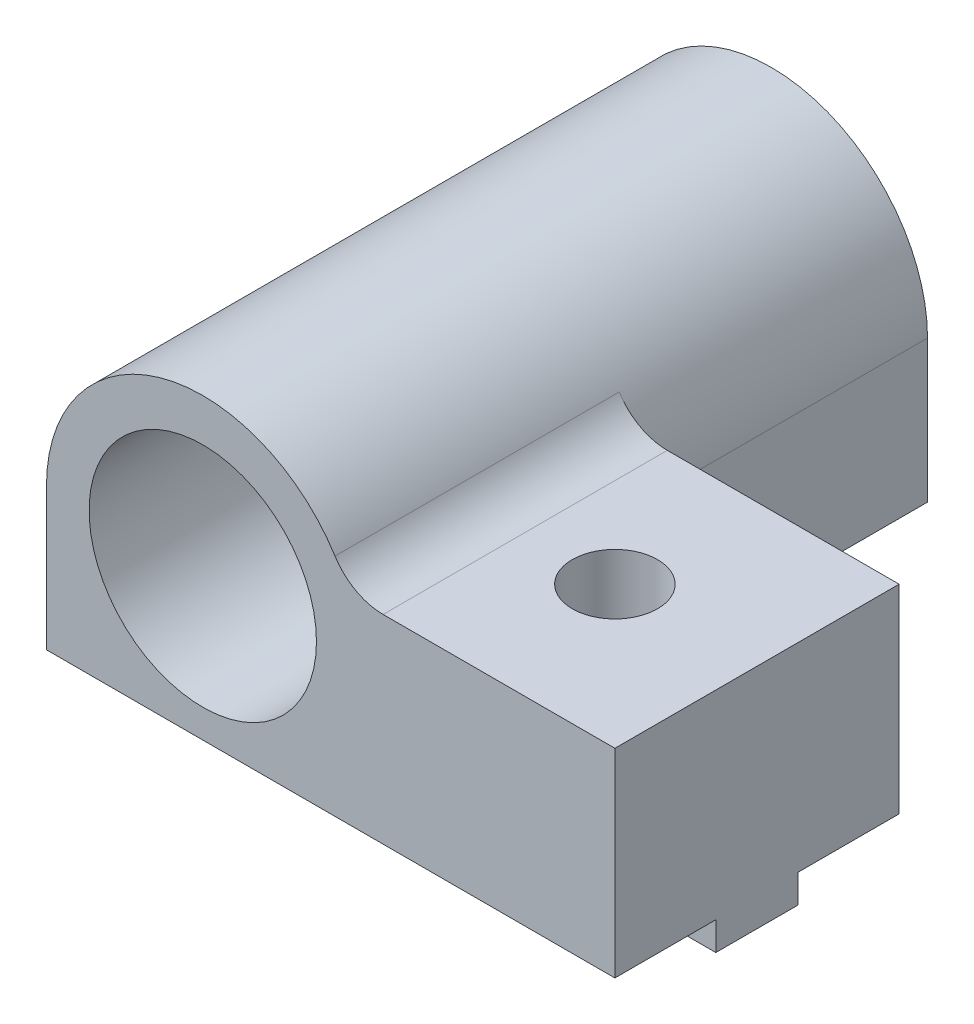
from build123d import *

# Parameters (mm, degrees)
SKETCH1_R                       = 4
MAIN_DEPTH                      = 10
SKETCH3_W                       = 20
SKETCH3_H                       = 2.9
MAKERBEAMRECTANGULARGUIDE_DEPTH = 1
SKETCH4_R                       = 1.5
MAKERBEAMFIXHOLE_DEPTH          = 9
FILLET1_R                       = 2
SKETCH5_R                       = 4
BOSS_EXTRUDE1_DEPTH             = 10
SKETCH6_W                       = 46.055005367
SKETCH6_H                       = 38.791045171
CUT_EXTRUDE1_DEPTH              = 26


with BuildPart() as part:
    # Sketch1 → Main (new body)
    with BuildSketch(Plane.XY):
        with BuildLine():
            Line((-5.5, 0), (-5.5, -5))
            Line((-5.5, -5), (14.5, -5))
            Line((14.5, -5), (14.5, 2))
            Line((14.5, 2), (5.123475383, 2))
            ThreePointArc((5.123475383, 2), (-1.017567048, 5.405049242), (-5.5, 0))
        make_face()
        Circle(SKETCH1_R, mode=Mode.SUBTRACT)
    extrude(amount=MAIN_DEPTH)

    # Sketch3 → MakerBeamRectangularGuide (add)
    with BuildSketch(Plane(origin=(0, -5, 0), x_dir=(-1, 0, 0), z_dir=(0, -1, 0))):
        with Locations((-4.5, -5)):
            Rectangle(SKETCH3_W, SKETCH3_H)
    extrude(amount=MAKERBEAMRECTANGULARGUIDE_DEPTH)

    # Sketch4 → MakerBeamFixHole (cut, through all)
    with BuildSketch(Plane(origin=(0, 2, 0), x_dir=(1, 0, 0), z_dir=(0, 1, 0))):
        with Locations((9.5, -5)):
            Circle(SKETCH4_R)
    extrude(amount=-MAKERBEAMFIXHOLE_DEPTH, mode=Mode.SUBTRACT)

    # Fillet1
    fillet1_edges = [part.edges().sort_by_distance(p)[0] for p in [
        (5.123475383, 2, 5),
    ]]
    fillet(fillet1_edges, radius=FILLET1_R)

    # Sketch5 → Boss-Extrude1 (add)
    with BuildSketch(Plane.XY.offset(10)):
        with BuildLine():
            Line((-5.5, -5), (5.5, -5))
            Line((5.5, -5), (5.5, 0))
            ThreePointArc((5.5, 0), (0, 5.5), (-5.5, 0))
            Line((-5.5, 0), (-5.5, -5))
        make_face()
        Circle(SKETCH5_R, mode=Mode.SUBTRACT)
    extrude(amount=BOSS_EXTRUDE1_DEPTH)


with BuildPart() as body_2:
    # Mirror1: mirrored copy
    add(part.part.mirror(Plane.XY.offset(-5)))


with BuildPart() as part_1:
    add(part.part)

    # Sketch6 → Cut-Extrude1 (cut, through all)
    with BuildSketch(Plane.XY.offset(-5)):
        with Locations((5.115796775, 3.309712685)):
            Rectangle(SKETCH6_W, SKETCH6_H)
    extrude(amount=CUT_EXTRUDE1_DEPTH, mode=Mode.SUBTRACT)


solid = body_2.part
